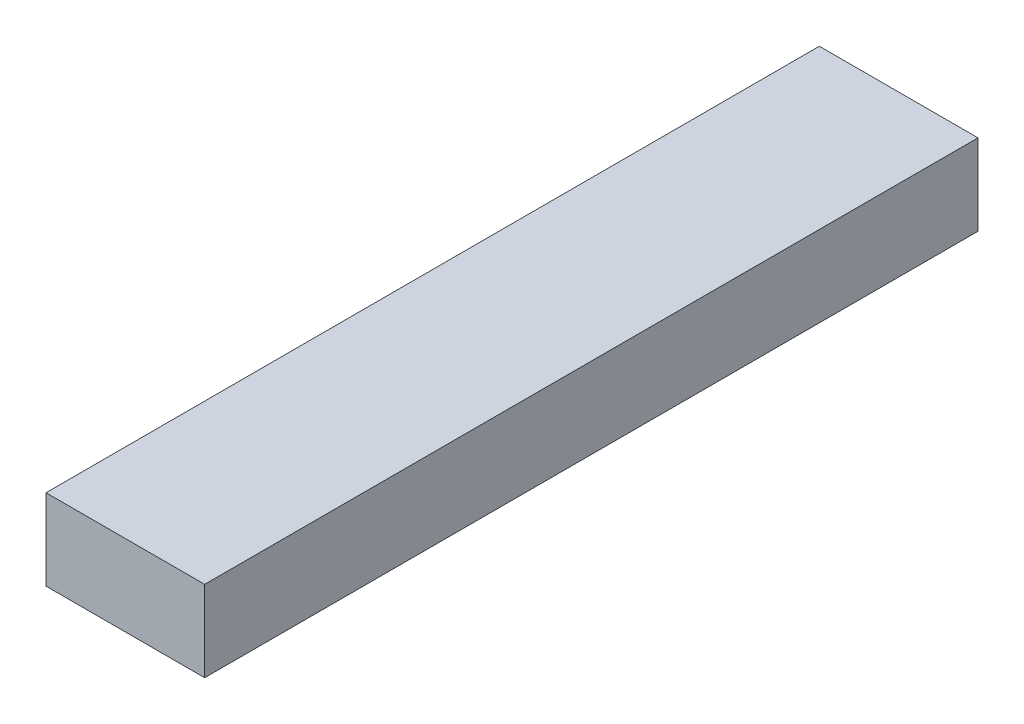
from build123d import *

# Parameters (mm, degrees)
J1HEADER_SKETCH_W       = 15.1
J1HEADER_SKETCH_H       = 73.6
J1_HEADER_EXTRUDE_DEPTH = 7.7


with BuildPart() as part:
    # J1Header Sketch → J1 Header Extrude (new body)
    with BuildSketch(Plane(origin=(0, 0, 0), x_dir=(1, 0, 0), z_dir=(0, 1, 0))):
        with Locations((7.55, 36.8)):
            Rectangle(J1HEADER_SKETCH_W, J1HEADER_SKETCH_H)
    extrude(amount=J1_HEADER_EXTRUDE_DEPTH)


solid = part.part
